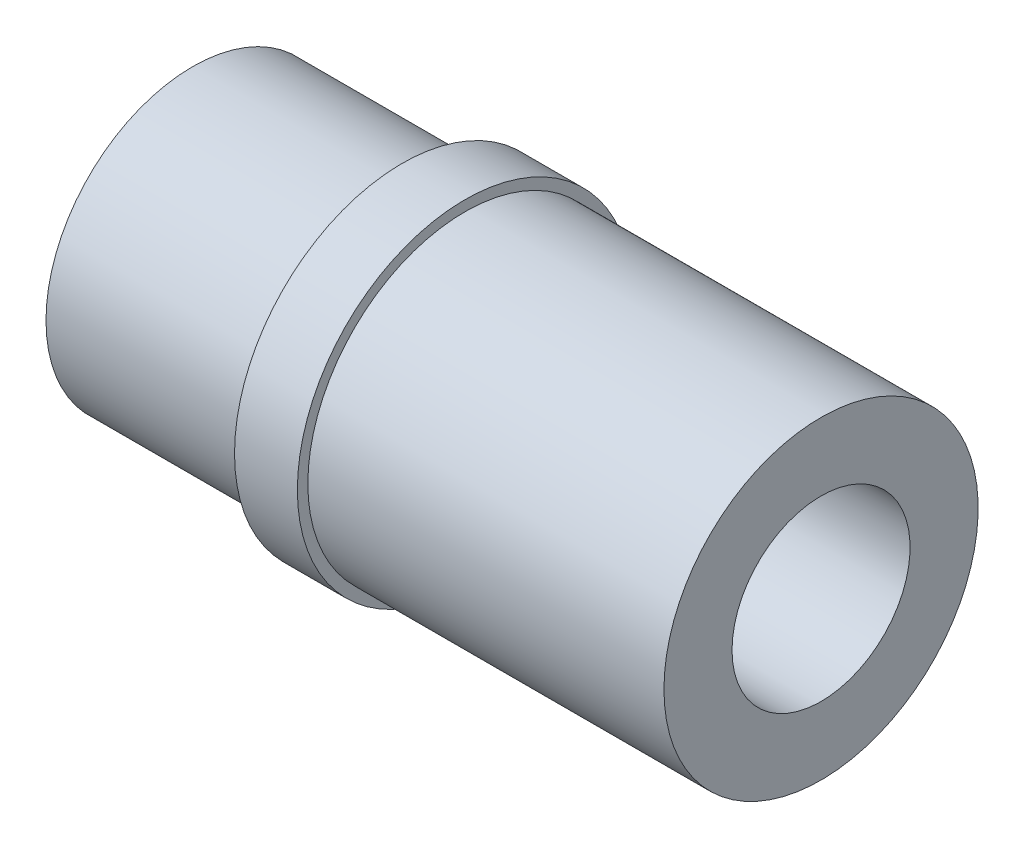
from build123d import *


with BuildPart() as part:
    # Sketch1 → Revolve1 (revolve)
    with BuildSketch(Plane.XY):
        Polygon((0, 5.5), (0, 7), (10, 7), (10, 8), (13, 8), (13, 7.5), (30, 7.5), (30, 4.25), (8.882962535, 4.25), align=None)
    revolve(axis=Axis((0, 0, 0), (1, 0, 0)))


solid = part.part
